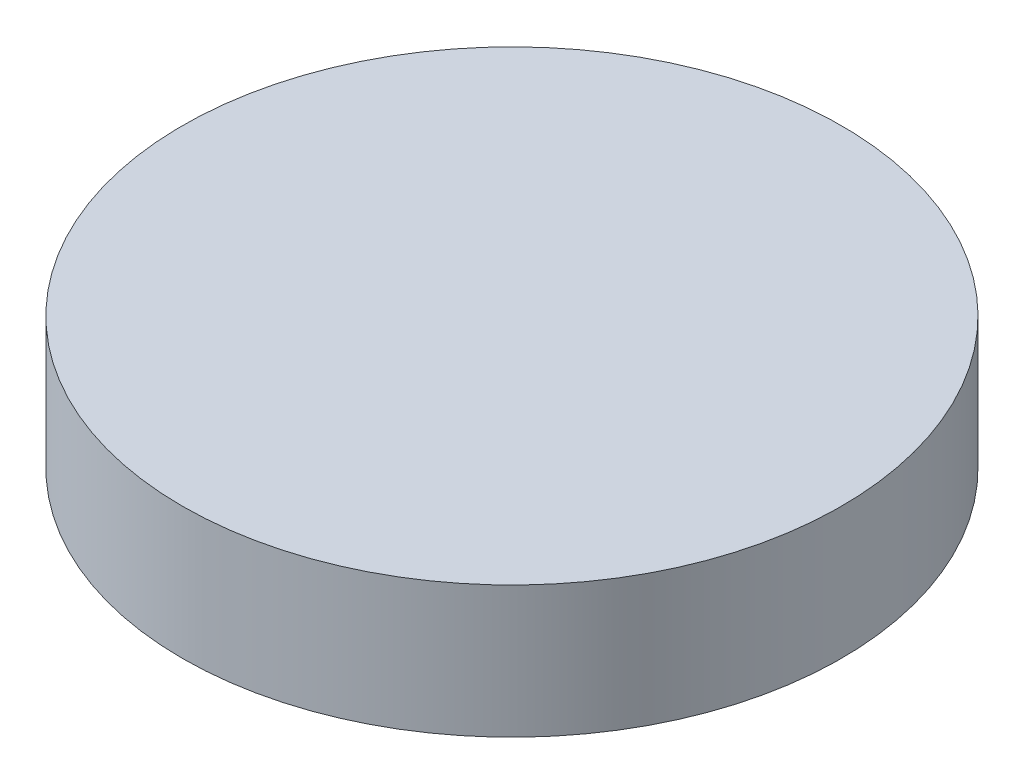
from build123d import *

# Parameters (mm, degrees)
SKETCH1_R           = 127
BOSS_EXTRUDE1_DEPTH = 50.8


with BuildPart() as part:
    # Sketch1 → Boss-Extrude1 (new body)
    with BuildSketch(Plane(origin=(0, 0, 0), x_dir=(1, 0, 0), z_dir=(0, 1, 0))):
        Circle(SKETCH1_R)
    extrude(amount=BOSS_EXTRUDE1_DEPTH)


solid = part.part
